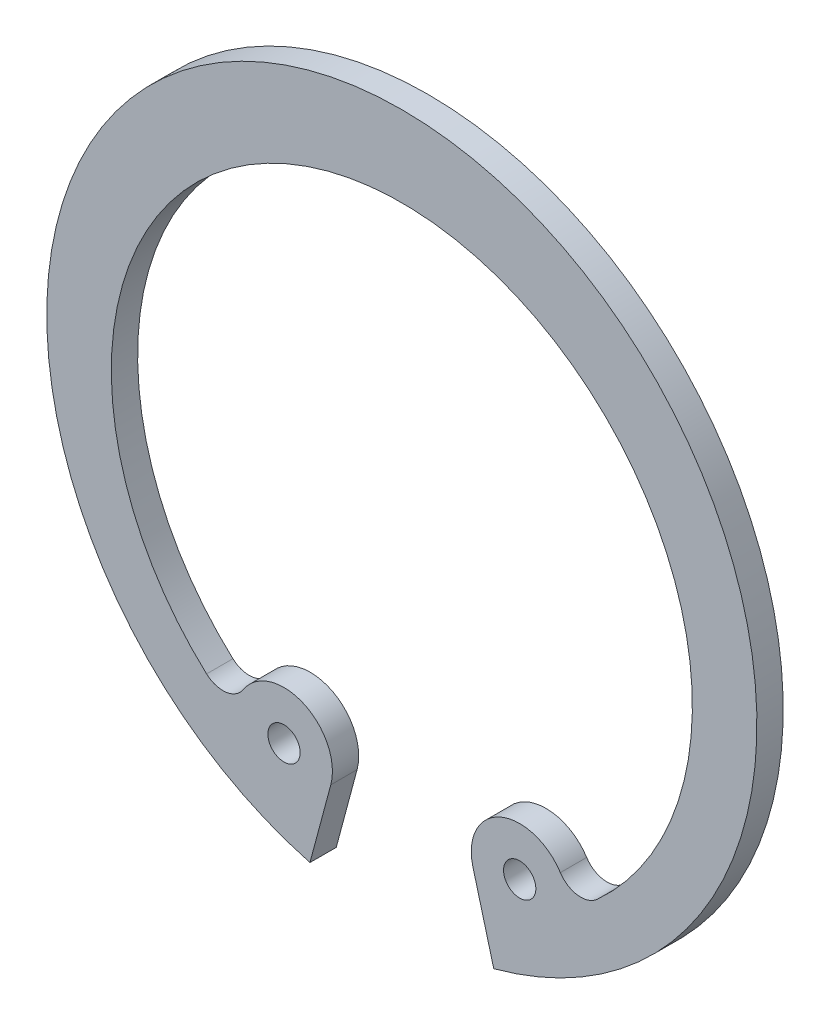
from build123d import *

# Parameters (mm, degrees)
ESQUISSE1_R          = 0.613636364
BASE_EXTRUSION_DEPTH = 1


with BuildPart() as part:
    # Esquisse1 → Base-Extrusion (new body)
    with BuildSketch(Plane.XY):
        with BuildLine():
            Line((-3.494057109, -13.039998655), (-2.702152167, -10.084569177))
            ThreePointArc((-2.702152167, -10.084569177), (-3.733830096, -7.925347652), (-6.026940189, -8.609630523))
            ThreePointArc((-6.026940189, -8.609630523), (-6.682827598, -9.024403146), (-7.423419677, -8.792567004))
            ThreePointArc((-7.423419677, -8.792567004), (0, 10.431818182), (7.423419677, -8.792567004))
            ThreePointArc((7.423419677, -8.792567004), (6.682827598, -9.024403146), (6.026940189, -8.609630523))
            ThreePointArc((6.026940189, -8.609630523), (3.733830096, -7.925347652), (2.702152167, -10.084569177))
            Line((2.702152167, -10.084569177), (3.494057109, -13.039998655))
            ThreePointArc((3.494057109, -13.039998655), (0, 13.5), (-3.494057109, -13.039998655))
        make_face()
        with Locations((-4.480333802, -9.608106844)):
            Circle(ESQUISSE1_R, mode=Mode.SUBTRACT)
        with Locations(Location((4.480333802, -9.608106844, 0), (0, 0, 180))):  # turned: the seam where the file's is
            Circle(ESQUISSE1_R, mode=Mode.SUBTRACT)
    extrude(amount=BASE_EXTRUSION_DEPTH)


solid = part.part
